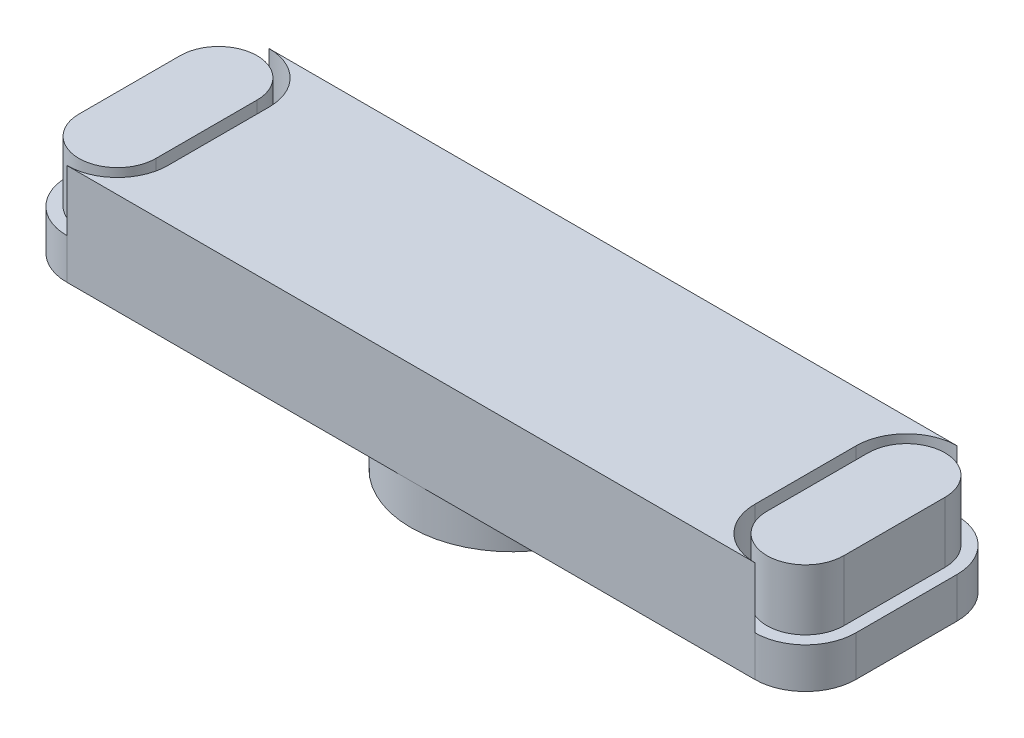
from build123d import *

# Parameters (mm, degrees)
BOSS_EXTRU_2_DEPTH      = 5
ESQUISSE1_9_R           = 5
ESQUISSE1_9_R_2         = 3.5
BOSS_EXTRU_7_DEPTH      = 7
ENL_V_MAT_EXTRU_3_DEPTH = 3
ENL_V_MAT_EXTRU_4_DEPTH = 3


with BuildPart() as part:
    # Esquisse1 → Boss.-Extru.2 (new body)
    with BuildSketch(Plane(origin=(0, 0, 0), x_dir=(1, 0, 0), z_dir=(0, 1, 0))):
        with BuildLine():
            ThreePointArc((17, -5), (18.767766953, -4.267766953), (19.5, -2.5))
            Line((19.5, -2.5), (19.5, 2.5))
            ThreePointArc((19.5, 2.5), (18.767766953, 4.267766953), (17, 5))
            Line((17, 5), (-17, 5))
            ThreePointArc((-17, 5), (-18.767766953, 4.267766953), (-19.5, 2.5))
            Line((-19.5, 2.5), (-19.5, -2.5))
            ThreePointArc((-19.5, -2.5), (-18.767766953, -4.267766953), (-17, -5))
            Line((-17, -5), (17, -5))
        make_face()
    extrude(amount=-BOSS_EXTRU_2_DEPTH)

    # Esquisse1_9 → Boss.-Extru.7 (add)
    with BuildSketch(Plane(origin=(0, 0, 0), x_dir=(1, 0, 0), z_dir=(0, 1, 0))):
        Circle(ESQUISSE1_9_R)
        Circle(ESQUISSE1_9_R_2, mode=Mode.SUBTRACT)
    extrude(amount=-BOSS_EXTRU_7_DEPTH)

    # Esquisse1_13 → Enl_v. mat.-Extru.3 (cut)
    with BuildSketch(Plane(origin=(0, 0, 0), x_dir=(1, 0, 0), z_dir=(0, 1, 0))):
        with BuildLine():
            ThreePointArc((14.5, -2.5), (17, -5), (19.5, -2.5))
            Line((19.5, -2.5), (19.5, 2.5))
            ThreePointArc((19.5, 2.5), (17, 5), (14.5, 2.5))
            Line((14.5, 2.5), (14.5, -2.5))
        make_face()
        with BuildLine():
            Line((15.1, -2.5), (15.1, 2.5))
            ThreePointArc((15.1, 2.5), (17, 4.4), (18.9, 2.5))
            Line((18.9, 2.5), (18.9, -2.5))
            ThreePointArc((18.9, -2.5), (17, -4.4), (15.1, -2.5))
        make_face(mode=Mode.SUBTRACT)
    extrude(amount=-ENL_V_MAT_EXTRU_3_DEPTH, mode=Mode.SUBTRACT)

    # Esquisse1_16 → Enl_v. mat.-Extru.4 (cut)
    with BuildSketch(Plane(origin=(0, 0, 0), x_dir=(1, 0, 0), z_dir=(0, 1, 0))):
        with BuildLine():
            ThreePointArc((-19.5, -2.5), (-17, -5), (-14.5, -2.5))
            Line((-14.5, -2.5), (-14.5, 2.5))
            ThreePointArc((-14.5, 2.5), (-17, 5), (-19.5, 2.5))
            Line((-19.5, 2.5), (-19.5, -2.5))
        make_face()
        with BuildLine():
            Line((-18.9, -2.5), (-18.9, 2.5))
            ThreePointArc((-18.9, 2.5), (-17, 4.4), (-15.1, 2.5))
            Line((-15.1, 2.5), (-15.1, -2.5))
            ThreePointArc((-15.1, -2.5), (-17, -4.4), (-18.9, -2.5))
        make_face(mode=Mode.SUBTRACT)
    extrude(amount=-ENL_V_MAT_EXTRU_4_DEPTH, mode=Mode.SUBTRACT)


solid = part.part
